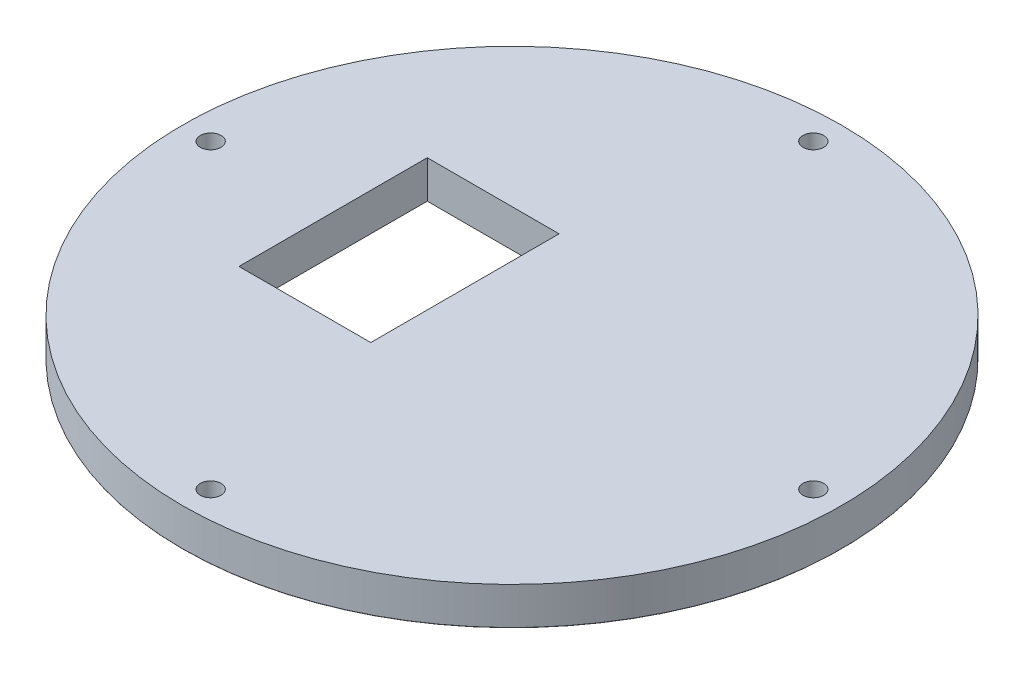
from build123d import *

# Parameters (mm, degrees)
SKETCH1_R                              = 87.5
BOSS_EXTRUDE1_DEPTH                    = 10
SKETCH2_R                              = 7.5
BOSS_EXTRUDE2_DEPTH                    = 80
CBORE_FOR_M5_HEX_HEAD_BOLT1_AT_2_COUNT = 2
CBORE_FOR_M5_HEX_HEAD_BOLT1_AT_2_PITCH = 113.13708499
CBORE_FOR_M5_HEX_HEAD_BOLT1_AT_3_COUNT = 2
CBORE_FOR_M5_HEX_HEAD_BOLT1_AT_3_PITCH = 160
CBORE_FOR_M5_HEX_HEAD_BOLT1_AT_4_COUNT = 2
CBORE_FOR_M5_HEX_HEAD_BOLT1_AT_4_PITCH = 113.13708499
SKETCH5_R                              = 87.5
CUT_EXTRUDE1_DEPTH                     = 80
FILLET1_R                              = 0.1
SKETCH10_W                             = 35
SKETCH10_H                             = 50
CUT_EXTRUDE3_DEPTH                     = 23
SKETCH12_W                             = 38
SKETCH12_H                             = 38
BOSS_EXTRUDE3_DEPTH                    = 6
SKETCH13_W                             = 22
SKETCH13_H                             = 6
BOSS_EXTRUDE4_DEPTH                    = 15
SKETCH14_W                             = 3
SKETCH14_H                             = 8
BOSS_EXTRUDE5_DEPTH                    = 13
CUT_EXTRUDE4_DEPTH                     = 93.0000001


with BuildPart() as part:
    # Sketch1 → Boss-Extrude1 (new body)
    with BuildSketch(Plane(origin=(0, 0, 0), x_dir=(1, 0, 0), z_dir=(0, 1, 0))):
        Circle(SKETCH1_R)
    extrude(amount=BOSS_EXTRUDE1_DEPTH)

    # Sketch2 → Boss-Extrude2 (add)
    with BuildSketch(Plane(origin=(0, 10, 0), x_dir=(1, 0, 0), z_dir=(0, 1, 0))):
        with Locations((0, -80)):
            Circle(SKETCH2_R)
        with Locations((-80, 0)):
            Circle(SKETCH2_R)
        with Locations((0, 80)):
            Circle(SKETCH2_R)
        with Locations((80, 0)):
            Circle(SKETCH2_R)
    extrude(amount=BOSS_EXTRUDE2_DEPTH)

    # Sketch4 → CBORE for M5 Hex Head Bolt1 (revolve, cut)
    with BuildSketch(Plane(origin=(80, 0, 0), x_dir=(0, 0, -1), z_dir=(1, 0, 0))):
        Polygon((0, 0), (0, 21.652366702), (2.75, 20), (2.75, 3.58), (6.12, 3.58), (6.12, 0.025), (6.145, 0), align=None)
    cbore_for_m5_hex_head_bolt1 = revolve(axis=Axis((80, -6.35, 0), (0, 1, 0)), mode=Mode.SUBTRACT)

    # CBORE for M5 Hex Head Bolt1 at 2: CBORE for M5 Hex Head Bolt1 ×2
    with Locations(*[Vector(-0.707106781, 0, -0.707106781) * (i * CBORE_FOR_M5_HEX_HEAD_BOLT1_AT_2_PITCH) for i in range(1, CBORE_FOR_M5_HEX_HEAD_BOLT1_AT_2_COUNT)]):
        add(cbore_for_m5_hex_head_bolt1, mode=Mode.SUBTRACT)

    # CBORE for M5 Hex Head Bolt1 at 3: CBORE for M5 Hex Head Bolt1 ×2
    with Locations(*[(-i * CBORE_FOR_M5_HEX_HEAD_BOLT1_AT_3_PITCH, 0, 0) for i in range(1, CBORE_FOR_M5_HEX_HEAD_BOLT1_AT_3_COUNT)]):
        add(cbore_for_m5_hex_head_bolt1, mode=Mode.SUBTRACT)

    # CBORE for M5 Hex Head Bolt1 at 4: CBORE for M5 Hex Head Bolt1 ×2
    with Locations(*[Vector(-0.707106781, 0, 0.707106781) * (i * CBORE_FOR_M5_HEX_HEAD_BOLT1_AT_4_PITCH) for i in range(1, CBORE_FOR_M5_HEX_HEAD_BOLT1_AT_4_COUNT)]):
        add(cbore_for_m5_hex_head_bolt1, mode=Mode.SUBTRACT)

    # Sketch5 → Cut-Extrude1 (cut)
    with BuildSketch(Plane(origin=(0, 10, 0), x_dir=(1, 0, 0), z_dir=(0, 1, 0))):
        Circle(SKETCH5_R)
    extrude(amount=CUT_EXTRUDE1_DEPTH, mode=Mode.SUBTRACT)

    # Fillet1
    fillet1_edges = [part.edges().sort_by_distance(p)[0] for p in [
        (-87.5, 0, 0),
    ]]
    fillet(fillet1_edges, radius=FILLET1_R)

    # Sketch10 → Cut-Extrude3 (cut)
    with BuildSketch(Plane(origin=(0, 10, 0), x_dir=(1, 0, 0), z_dir=(0, 1, 0))):
        with Locations((-30, 0)):
            Rectangle(SKETCH10_W, SKETCH10_H)
    extrude(amount=-CUT_EXTRUDE3_DEPTH, mode=Mode.SUBTRACT)

    # Sketch12 → Boss-Extrude3 (add)
    with BuildSketch(Plane.XZ):
        with Locations((6.5, 0)):
            Rectangle(SKETCH12_W, SKETCH12_H)
        Polygon((22.5, 16), (17.5, 16), (17.5, 13), (-4.5, 13), (-4.5, 16), (-9.5, 16), (-9.5, -16), (-4.5, -16), (-4.5, -13), (17.5, -13), (17.5, -16), (22.5, -16), align=None, mode=Mode.SUBTRACT)
    extrude(amount=BOSS_EXTRUDE3_DEPTH)

    # Sketch13 → Boss-Extrude4 (add)
    with BuildSketch(Plane.XZ.offset(6)):
        with Locations((6.5, 16)):
            Rectangle(SKETCH13_W, SKETCH13_H)
        with Locations((6.5, -16)):
            Rectangle(SKETCH13_W, SKETCH13_H)
    extrude(amount=BOSS_EXTRUDE4_DEPTH)

    # Sketch14 → Boss-Extrude5 (add)
    with BuildSketch(Plane.XZ.offset(6)):
        with Locations((24, 0)):
            Rectangle(SKETCH14_W, SKETCH14_H)
    extrude(amount=BOSS_EXTRUDE5_DEPTH)

    # Sketch15 → Cut-Extrude4 (cut, through all)
    with BuildSketch(Plane.ZY.offset(4.5)):
        with BuildLine():
            ThreePointArc((-13.500000002, -17.1), (-12.4, -16.000000001), (-13.5, -14.9))
            ThreePointArc((-13.5, -14.9), (-14.6, -15.999999999), (-13.500000002, -17.1))
        make_face()
        with BuildLine():
            ThreePointArc((13.500000002, -17.1), (14.6, -15.999999999), (13.5, -14.9))
            ThreePointArc((13.5, -14.9), (12.4, -16.000000001), (13.500000002, -17.1))
        make_face()
    extrude(amount=-CUT_EXTRUDE4_DEPTH, mode=Mode.SUBTRACT)


solid = part.part
